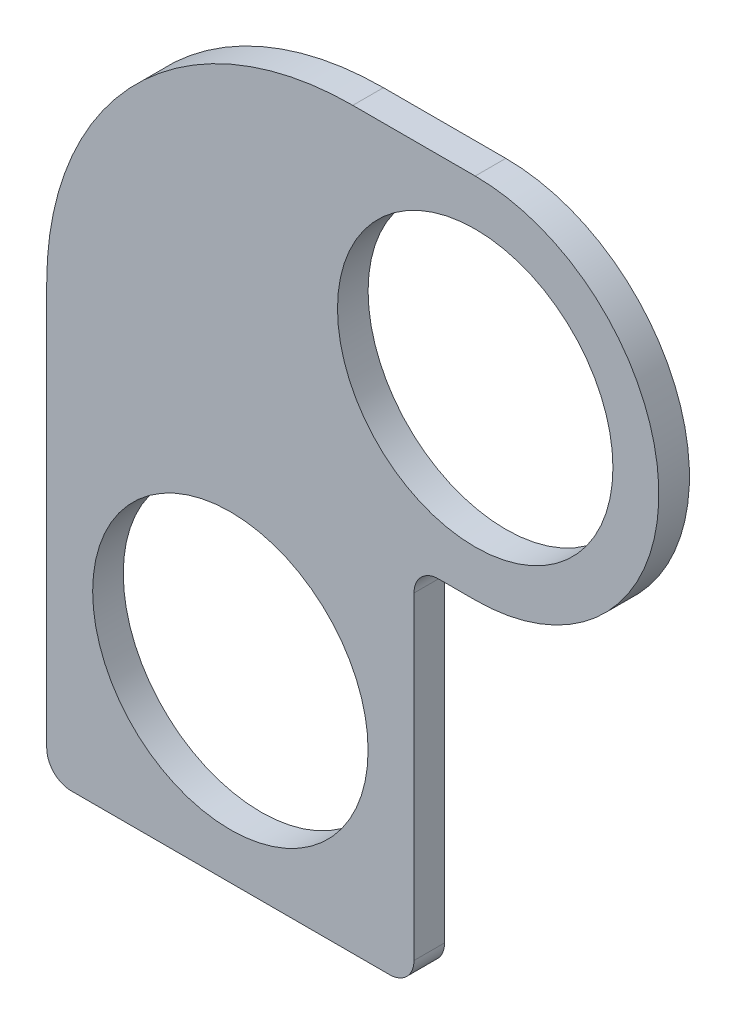
from build123d import *

# Parameters (mm, degrees)
SKETCH1_R           = 14.2875
BOSS_EXTRUDE1_DEPTH = 3.175
FILLET1_R           = 2.54


with BuildPart() as part:
    # Sketch1 → Boss-Extrude1 (new body)
    with BuildSketch(Plane.XY):
        with BuildLine():
            Line((25.4, -19.05), (19.05, -19.05))
            Line((19.05, -19.05), (19.05, -57.15))
            Line((19.05, -57.15), (-19.05, -57.15))
            Line((-19.05, -57.15), (-19.05, -19.05))
            Line((-19.05, -19.05), (-19.05, -12.7))
            ThreePointArc((-19.05, -12.7), (-9.750640303, 9.750640303), (12.7, 19.05))
            Line((12.7, 19.05), (25.4, 19.05))
            ThreePointArc((25.4, 19.05), (44.45, 0), (25.4, -19.05))
        make_face()
        with Locations((25.4, 0)):
            Circle(SKETCH1_R, mode=Mode.SUBTRACT)
        with Locations((0, -38.1)):
            Circle(SKETCH1_R, mode=Mode.SUBTRACT)
    extrude(amount=BOSS_EXTRUDE1_DEPTH)

    # Fillet1
    fillet1_edges = [part.edges().sort_by_distance(p)[0] for p in [
        (19.05, -19.05, 1.5875),
        (19.05, -57.15, 1.5875),
        (-19.05, -57.15, 1.5875),
    ]]
    fillet(fillet1_edges, radius=FILLET1_R)


solid = part.part
